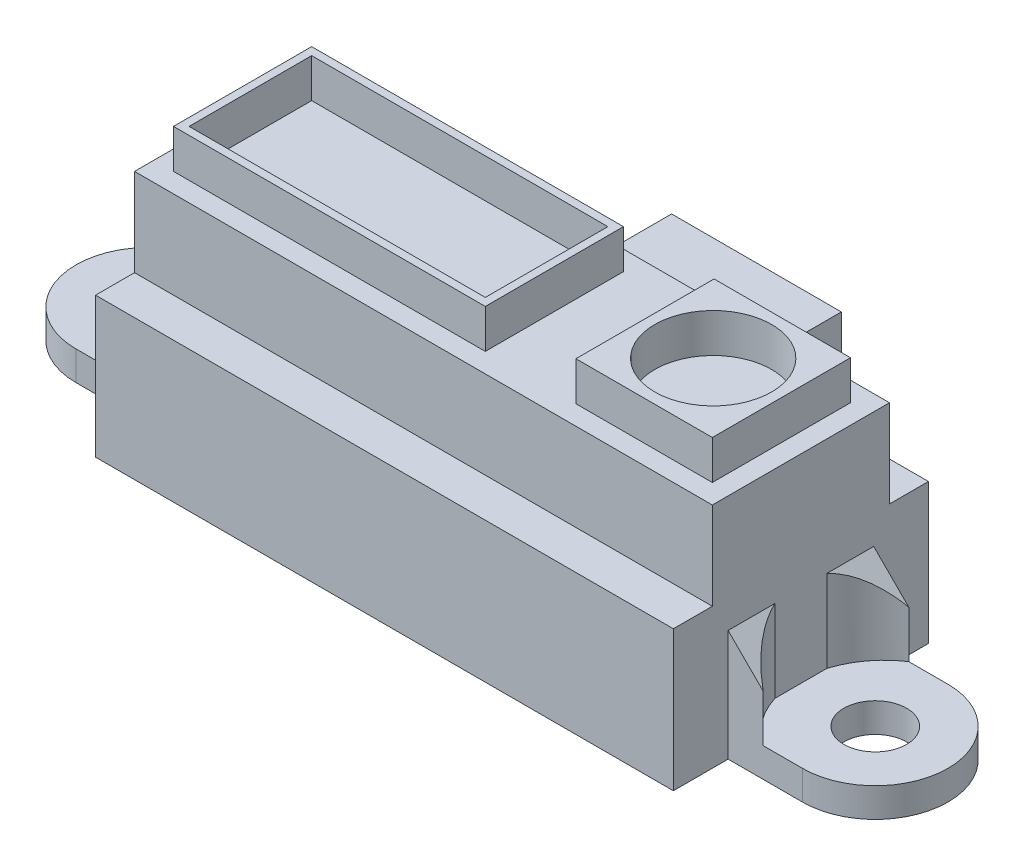
from build123d import *

# Parameters (mm, degrees)
BOSS_EXTRUDE1_DEPTH     = 7.2
SKETCH2_R               = 1.61
BOSS_EXTRUDE2_DEPTH     = 1.5
BOSS_EXTRUDE3_DEPTH     = 0.7
BOSS_EXTRUDE7_DEPTH     = 4.22
CUT_EXTRUDE1_DEPTH      = 7.544999991
CUT_EXTRUDE1_DEPTH_BACK = 7.544999991
ESQUISSE1_W             = 29.65
ESQUISSE1_H             = 9.089999982
BOSS_EXTRU_1_DEPTH      = 4.5
ESQUISSE3_W             = 16
ESQUISSE3_H             = 7.089999982
ESQUISSE3_W_2           = 7
BOSS_EXTRU_2_DEPTH      = 2
ESQUISSE4_R             = 3
ESQUISSE4_W             = 15.2
ESQUISSE4_H             = 6.289999982
ENL_V_MAT_EXTRU_1_DEPTH = 2
ESQUISSE5_W             = 8.71
ESQUISSE5_H             = 1
BOSS_EXTRU_3_DEPTH      = 8
BOSS_EXTRU_4_DEPTH      = 8


with BuildPart() as part:
    # Sketch1 → Boss-Extrude1 (new body)
    with BuildSketch(Plane(origin=(0, 0, 0), x_dir=(1, 0, 0), z_dir=(0, 1, 0))):
        Polygon((-14.055, 5.774999991), (-5.355, 5.774999991), (-5.355, 6.544999991), (-14.825, 6.544999991), (-14.825, -6.544999991), (14.825, -6.544999991), (14.825, 6.544999991), (5.355, 6.544999991), (5.355, 5.774999991), (14.055, 5.774999991), (14.055, -5.774999991), (-14.055, -5.774999991), align=None)
    extrude(amount=BOSS_EXTRUDE1_DEPTH)

    # Sketch2 → Boss-Extrude2 (add)
    with BuildSketch(Plane(origin=(0, 0, 0), x_dir=(1, 0, 0), z_dir=(0, 1, 0))):
        with BuildLine():
            Line((18.64, 3.735), (14.825, 3.735))
            Line((14.825, 3.735), (14.825, -3.735))
            Line((14.825, -3.735), (18.64, -3.735))
            ThreePointArc((18.64, -3.735), (22.375, 0), (18.64, 3.735))
        make_face()
        with Locations((18.64, 0)):
            Circle(SKETCH2_R, mode=Mode.SUBTRACT)
        with BuildLine():
            Line((-14.825, 3.735), (-14.825, -3.735))
            Line((-14.825, -3.735), (-18.64, -3.735))
            ThreePointArc((-18.64, -3.735), (-22.375, 0), (-18.64, 3.735))
            Line((-18.64, 3.735), (-14.825, 3.735))
        make_face()
        with Locations((-18.64, 0)):
            Circle(SKETCH2_R, mode=Mode.SUBTRACT)
    extrude(amount=BOSS_EXTRUDE2_DEPTH)

    # Sketch3 → Boss-Extrude3 (add)
    with BuildSketch(Plane(origin=(0, 7.2, 0), x_dir=(1, 0, 0), z_dir=(0, 1, 0))):
        Polygon((-14.825, -6.544999991), (14.825, -6.544999991), (14.825, 6.544999991), (5.355, 6.544999991), (5.355, 4.324999991), (-5.355, 4.324999991), (-5.355, 6.544999991), (-14.825, 6.544999991), align=None)
    extrude(amount=-BOSS_EXTRUDE3_DEPTH)

    # Sketch7 → Boss-Extrude7 (add)
    with BuildSketch(Plane(origin=(0, 1.5, 0), x_dir=(1, 0, 0), z_dir=(0, 1, 0))):
        with BuildLine():
            Line((-14.825, 3.735), (-16.625, 3.735))
            ThreePointArc((-16.625, 3.735), (-15.518302355, 2.690023234), (-14.825, 1.335))
            Line((-14.825, 1.335), (-14.825, 3.735))
        make_face()
        with BuildLine():
            Line((-14.825, -3.735), (-14.825, -1.335))
            ThreePointArc((-14.825, -1.335), (-15.518302355, -2.690023234), (-16.625, -3.735))
            Line((-16.625, -3.735), (-14.825, -3.735))
        make_face()
        with BuildLine():
            Line((14.825, -3.735), (16.625, -3.735))
            ThreePointArc((16.625, -3.735), (15.518302355, -2.690023234), (14.825, -1.335))
            Line((14.825, -1.335), (14.825, -3.735))
        make_face()
        with BuildLine():
            Line((14.825, 3.735), (14.825, 1.335))
            ThreePointArc((14.825, 1.335), (15.518302355, 2.690023234), (16.625, 3.735))
            Line((16.625, 3.735), (14.825, 3.735))
        make_face()
    extrude(amount=BOSS_EXTRUDE7_DEPTH)

    # Sketch8 → Cut-Extrude1 (cut, two sides)
    with BuildSketch(Plane.XY) as cut_extrude1_sk:
        Polygon((-14.825, 5.72), (-16.625, 3.92), (-16.625, 5.72), align=None)
        Polygon((14.825, 5.72), (16.625, 3.92), (16.625, 5.72), align=None)
    extrude(amount=CUT_EXTRUDE1_DEPTH, mode=Mode.SUBTRACT)
    extrude(cut_extrude1_sk.sketch, amount=-CUT_EXTRUDE1_DEPTH_BACK, mode=Mode.SUBTRACT)

    # Esquisse1 → Boss.-Extru.1 (add)
    with BuildSketch(Plane(origin=(0, 7.2, 0), x_dir=(1, 0, 0), z_dir=(0, 1, 0))):
        Rectangle(ESQUISSE1_W, ESQUISSE1_H)
    extrude(amount=BOSS_EXTRU_1_DEPTH)

    # Esquisse3 → Boss.-Extru.2 (add)
    with BuildSketch(Plane(origin=(0, 11.7, 0), x_dir=(1, 0, 0), z_dir=(0, 1, 0))):
        with Locations((-5.825, 0)):
            Rectangle(ESQUISSE3_W, ESQUISSE3_H)
        with Locations((10.325, 0)):
            Rectangle(ESQUISSE3_W_2, ESQUISSE3_H)
    extrude(amount=BOSS_EXTRU_2_DEPTH)

    # Esquisse4 → Enlèv. mat.-Extru.1 (cut)
    with BuildSketch(Plane(origin=(0, 13.7, 0), x_dir=(1, 0, 0), z_dir=(0, 1, 0))):
        with Locations((10.325, 0)):
            Circle(ESQUISSE4_R)
        with Locations((-5.825, 0)):
            Rectangle(ESQUISSE4_W, ESQUISSE4_H)
    extrude(amount=-ENL_V_MAT_EXTRU_1_DEPTH, mode=Mode.SUBTRACT)

    # Esquisse5 → Boss.-Extru.3 (add)
    with BuildSketch(Plane.XZ.offset(-6.5)):
        with Locations((0, -4.044999991)):
            Rectangle(ESQUISSE5_W, ESQUISSE5_H)
    extrude(amount=BOSS_EXTRU_3_DEPTH)

    # Esquisse6 → Boss.-Extru.4 (add)
    with BuildSketch(Plane(origin=(0, 0, -4.544999991), x_dir=(-1, 0, 0), z_dir=(0, 0, -1))):
        Polygon((-4.355, -1.5), (-3.355, -1.5), (-3.355, 5.5), (3.355, 5.5), (3.355, -1.5), (4.355, -1.5), (4.355, 6.5), (-4.355, 6.5), align=None)
    extrude(amount=BOSS_EXTRU_4_DEPTH)


solid = part.part
